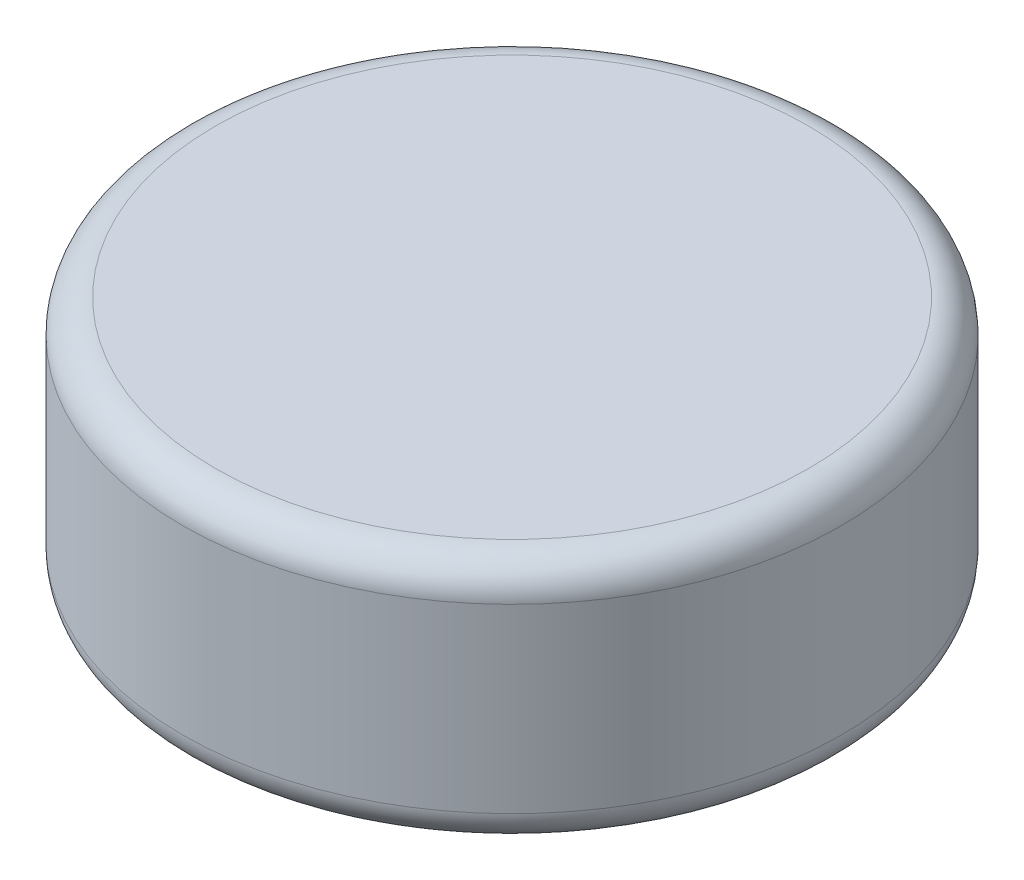
from build123d import *

# Parameters (mm, degrees)
SKETCH1_R           = 2
BOSS_EXTRUDE1_DEPTH = 1.5
FILLET1_R           = 0.2


with BuildPart() as part:
    # Sketch1 → Boss-Extrude1 (new body)
    with BuildSketch(Plane(origin=(0, 0, 0), x_dir=(1, 0, 0), z_dir=(0, 1, 0))):
        Circle(SKETCH1_R)
    extrude(amount=BOSS_EXTRUDE1_DEPTH)

    # Fillet1
    fillet1_edges = [part.edges().sort_by_distance(p)[0] for p in [
        (-2, 0, 0),
        (-2, 1.5, 0),
    ]]
    fillet(fillet1_edges, radius=FILLET1_R)


solid = part.part
